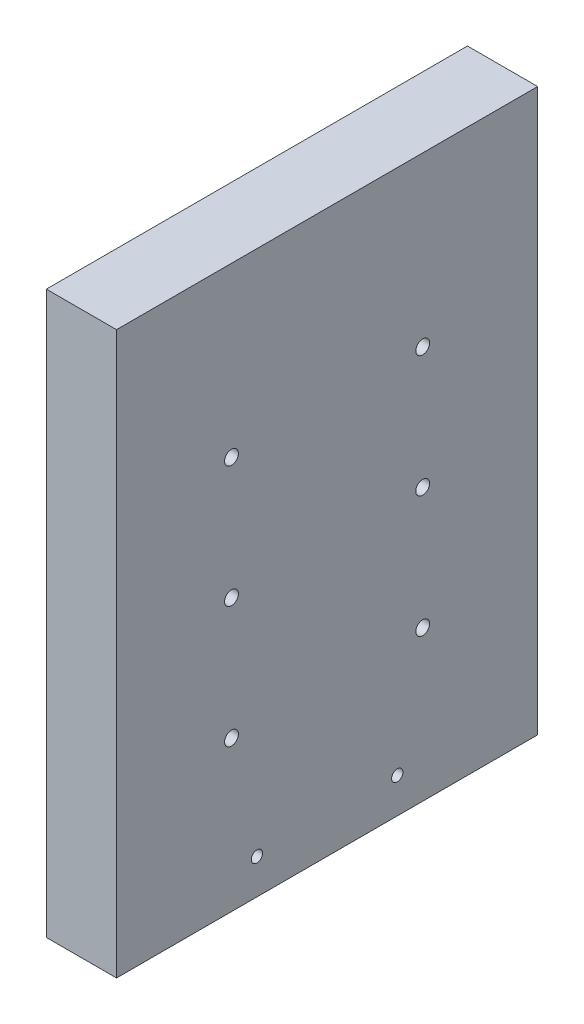
from build123d import *

# Parameters (mm, degrees)
SKETCH2_W                          = 76.2
SKETCH2_H                          = 101.6
BOSS_EXTRUDE2_DEPTH                = 12.7
F_2_5MM_DOWEL_HOLE1_D              = 2.5
SKETCH5_R                          = 5
CUT_EXTRUDE1_DEPTH                 = 2.5
TAP_DRILL_FOR_M2_5X0_45_TAP1_D     = 2.05
TAP_DRILL_FOR_M2_5X0_45_TAP1_DEPTH = 12.7
TAP_DRILL_FOR_M2_5X0_45_TAP1_TIP   = 0.615882135


with BuildPart() as part:
    # Sketch2 → Boss-Extrude2 (new body)
    with BuildSketch(Plane(origin=(0, 0, 0), x_dir=(0, 0, -1), z_dir=(1, 0, 0))):
        with Locations((0, 50.8)):
            Rectangle(SKETCH2_W, SKETCH2_H)
    extrude(amount=BOSS_EXTRUDE2_DEPTH)

    # Ø2.5mm Dowel Hole1 (through all)
    with Locations(Plane.ZY):
        with Locations((-17.3, 71.2), (-17.3, 49.2), (-17.3, 27.2)):
            f_2_5mm_dowel_hole1 = Hole(F_2_5MM_DOWEL_HOLE1_D / 2)

    # Mirror1: Ø2.5mm Dowel Hole1 across plane
    add(f_2_5mm_dowel_hole1.mirror(Plane.XY), mode=Mode.SUBTRACT)

    # Sketch5 → Cut-Extrude1 (cut)
    with BuildSketch(Plane.ZY):
        with Locations((0, 67.2)):
            Circle(SKETCH5_R)
    extrude(amount=-CUT_EXTRUDE1_DEPTH, mode=Mode.SUBTRACT)

    # Tap Drill for M2.5x0.45 Tap1
    with Locations(Plane(origin=(12.7, 0, 0), x_dir=(0, 0, -1), z_dir=(1, 0, 0))):
        with Locations((-12.7, 6.35), (12.7, 6.35)):
            Hole(TAP_DRILL_FOR_M2_5X0_45_TAP1_D / 2, depth=TAP_DRILL_FOR_M2_5X0_45_TAP1_DEPTH)
            with Locations((0, 0, -(TAP_DRILL_FOR_M2_5X0_45_TAP1_DEPTH + TAP_DRILL_FOR_M2_5X0_45_TAP1_TIP / 2))):  # 118° drill point
                Cone(0, TAP_DRILL_FOR_M2_5X0_45_TAP1_D / 2, TAP_DRILL_FOR_M2_5X0_45_TAP1_TIP, mode=Mode.SUBTRACT)


solid = part.part
